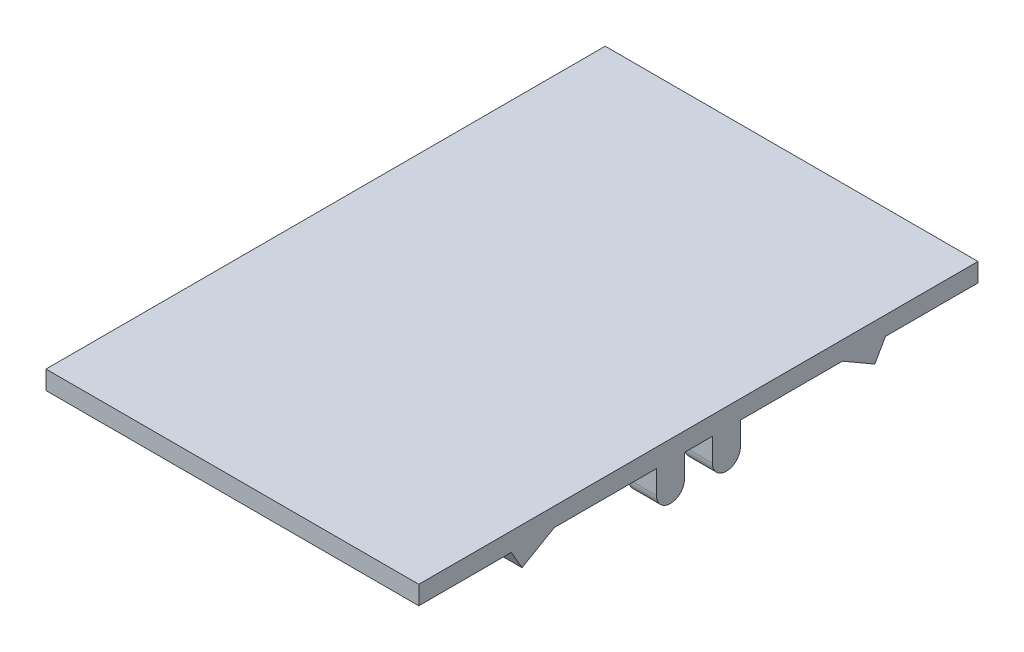
from build123d import *

# Parameters (mm, degrees)
SKETCH1_W            = 400
SKETCH1_H            = 600
BOSS_EXTRUDE1_DEPTH  = 20
BOSS_EXTRUDE2_DEPTH  = 30
MIRROR2_COPY_1_DEPTH = 30
BOSS_EXTRUDE3_DEPTH  = 30
MIRROR4_COPY_1_DEPTH = 30


with BuildPart() as part:
    # Sketch1 → Boss-Extrude1 (new body)
    with BuildSketch(Plane(origin=(0, 0, 0), x_dir=(1, 0, 0), z_dir=(0, 1, 0))):
        Rectangle(SKETCH1_W, SKETCH1_H)
    extrude(amount=BOSS_EXTRUDE1_DEPTH)

    # Sketch3 → Boss-Extrude2 (add)
    with BuildSketch(Plane(origin=(200, 0, 0), x_dir=(0, 0, -1), z_dir=(1, 0, 0))):
        with BuildLine():
            Line((-45, -25), (-45, 0))
            Line((-45, 0), (-15, 0))
            Line((-15, 0), (-15, -25))
            ThreePointArc((-15, -25), (-30, -40), (-45, -25))
        make_face()
    boss_extrude2 = extrude(amount=-BOSS_EXTRUDE2_DEPTH)

    # Mirror1: Boss-Extrude2 across plane
    add(boss_extrude2.mirror(Plane.XY))

    # Mirror2: Boss-Extrude2 across plane
    add(boss_extrude2.mirror(Plane(origin=(0, 0, 0), x_dir=(0, 0, 1), z_dir=(1, 0, 0))))

    # Mirror2 copy 1 sketch → Mirror2 copy 1 (add)
    with BuildSketch(Plane.ZY.offset(200)):
        with BuildLine():
            Line((-45, -25), (-45, 0))
            Line((-45, 0), (-15, 0))
            Line((-15, 0), (-15, -25))
            ThreePointArc((-15, -25), (-30, -40), (-45, -25))
        make_face()
    extrude(amount=-MIRROR2_COPY_1_DEPTH)

    # Sketch4 → Boss-Extrude3 (add)
    with BuildSketch(Plane(origin=(200, 0, 0), x_dir=(0, 0, -1), z_dir=(1, 0, 0))):
        Polygon((-154.598033597, 0), (-189.239049749, -20), (-200.786055132, 0), align=None)
    boss_extrude3 = extrude(amount=-BOSS_EXTRUDE3_DEPTH)

    # Mirror3: Boss-Extrude3 across plane
    add(boss_extrude3.mirror(Plane(origin=(0, 0, 0), x_dir=(0, 0, 1), z_dir=(1, 0, 0))))

    # Mirror4: Boss-Extrude3 across plane
    add(boss_extrude3.mirror(Plane.XY))

    # Mirror4 copy 1 sketch → Mirror4 copy 1 (add)
    with BuildSketch(Plane.ZY.offset(200)):
        Polygon((-154.598033597, 0), (-189.239049749, -20), (-200.786055132, 0), align=None)
    extrude(amount=-MIRROR4_COPY_1_DEPTH)


solid = part.part
